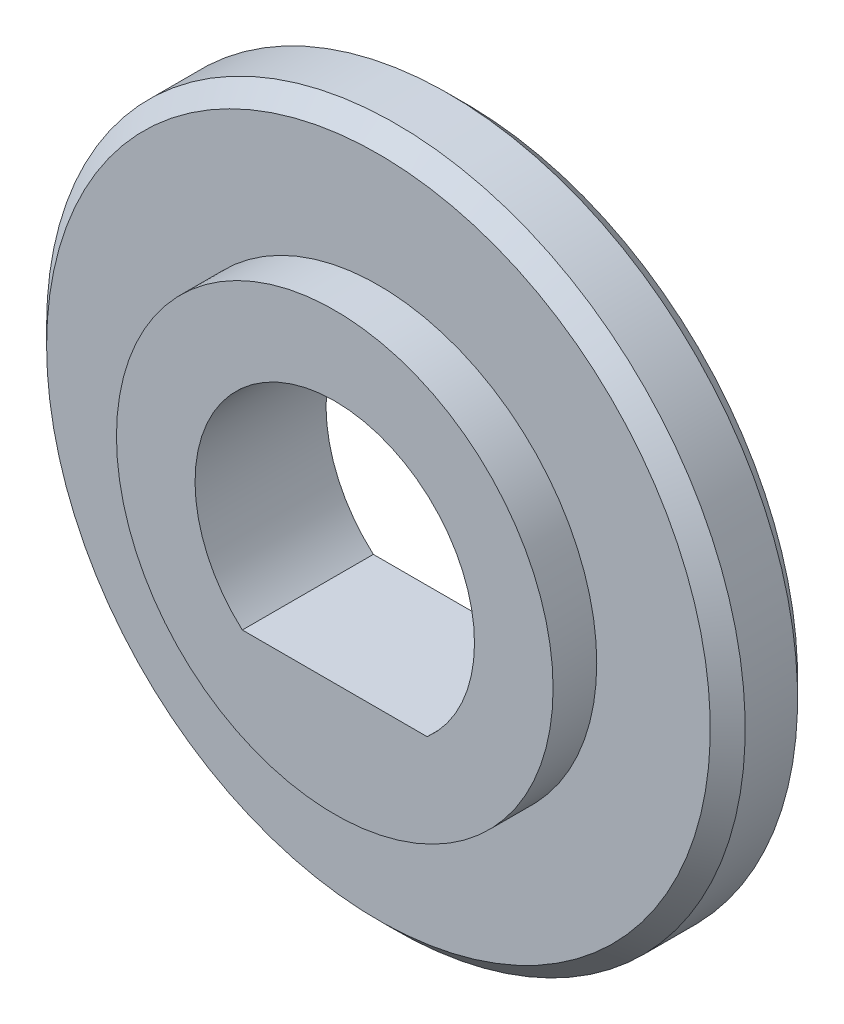
from build123d import *

# Parameters (mm, degrees)
SKETCH1_R           = 12.5
SKETCH1_R_2         = 8
BOSS_EXTRUDE1_DEPTH = 2.5
SKETCH3_R           = 20
SKETCH3_R_2         = 8
BOSS_EXTRUDE3_DEPTH = 5
CHAMFER2_SIZE       = 1
SKETCH4_W           = 11
SKETCH4_H           = 7.5
BOSS_EXTRUDE4_DEPTH = 3


with BuildPart() as part:
    # Sketch1 → Boss-Extrude1 (new body)
    with BuildSketch(Plane.XY):
        Circle(SKETCH1_R)
        Circle(SKETCH1_R_2, mode=Mode.SUBTRACT)
    extrude(amount=BOSS_EXTRUDE1_DEPTH)

    # Sketch3 → Boss-Extrude3 (add)
    with BuildSketch(Plane(origin=(0, 0, 0), x_dir=(-1, 0, 0), z_dir=(0, 0, -1))):
        Circle(SKETCH3_R)
        Circle(SKETCH3_R_2, mode=Mode.SUBTRACT)
    extrude(amount=BOSS_EXTRUDE3_DEPTH)

    # Chamfer2
    chamfer2_edges = [part.edges().sort_by_distance(p)[0] for p in [
        (20, 0, 0),
        (20, 0, -5),
    ]]
    chamfer(chamfer2_edges, length=CHAMFER2_SIZE)

    # Sketch4 → Boss-Extrude4 (add)
    with BuildSketch(Plane(origin=(0, -6, 0), x_dir=(-1, 0, 0), z_dir=(0, 1, 0))):
        with Locations((0, -1.25)):
            Rectangle(SKETCH4_W, SKETCH4_H)
    extrude(amount=-BOSS_EXTRUDE4_DEPTH)


solid = part.part
